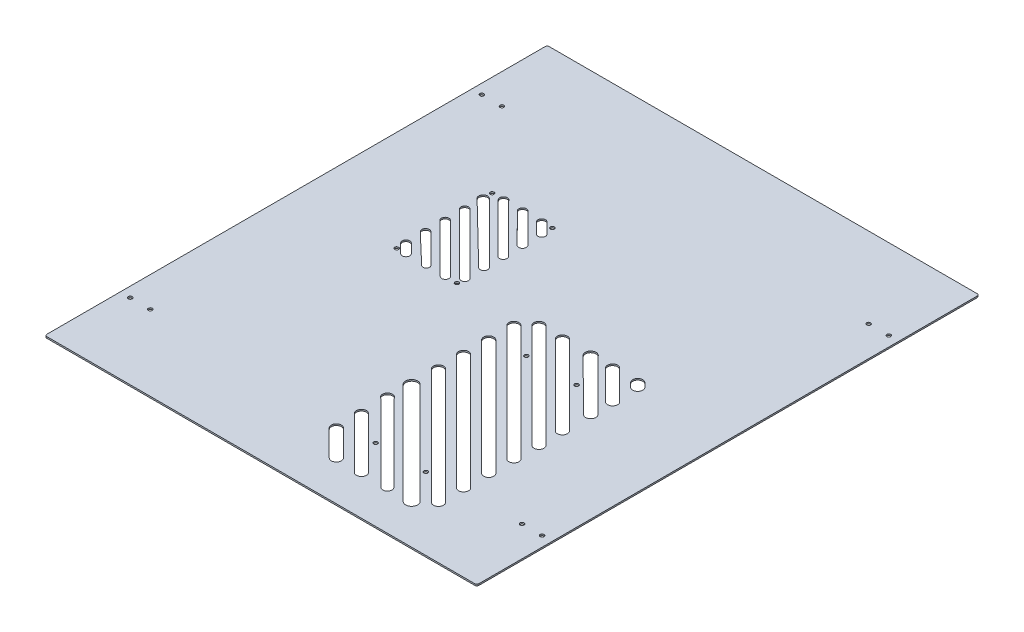
from build123d import *

# Parameters (mm, degrees)
SKETCH1_W           = 430
SKETCH1_H           = 500
BOSS_EXTRUDE1_DEPTH = 1.5
SKETCH12_R          = 1.95
CUT_EXTRUDE3_DEPTH  = 50.8
SKETCH6_R           = 1.95
CUT_EXTRUDE4_DEPTH  = 50.8
SKETCH7_R           = 1.95
CUT_EXTRUDE5_DEPTH  = 50.8
FILLET1_R           = 2
CUT_EXTRUDE6_DEPTH  = 10


with BuildPart() as part:
    # Sketch1 → Boss-Extrude1 (new body)
    with BuildSketch(Plane(origin=(0, 0, 0), x_dir=(1, 0, 0), z_dir=(0, 1, 0))):
        Rectangle(SKETCH1_W, SKETCH1_H)
    extrude(amount=BOSS_EXTRUDE1_DEPTH)

    # Sketch12 → Cut-Extrude3 (cut)
    with BuildSketch(Plane(origin=(0, 0, 0), x_dir=(-1, 0, 0), z_dir=(0, -1, 0))):
        with Locations((-185, -175)):
            Circle(SKETCH12_R)
        with Locations((-205, 170)):
            Circle(SKETCH12_R)
        with Locations((-205, -175)):
            Circle(SKETCH12_R)
        with Locations((-185, 170)):
            Circle(SKETCH12_R)
        with Locations((205, -175)):
            Circle(SKETCH12_R)
        with Locations((185, 175)):
            Circle(SKETCH12_R)
        with Locations((205, 175)):
            Circle(SKETCH12_R)
        with Locations((185, -175)):
            Circle(SKETCH12_R)
    extrude(amount=-CUT_EXTRUDE3_DEPTH, mode=Mode.SUBTRACT)

    # Sketch6 → Cut-Extrude4 (cut)
    with BuildSketch(Plane(origin=(0, 1.5, 0), x_dir=(1, 0, 0), z_dir=(0, 1, 0))):
        with Locations((92.292697989, -28)):
            Circle(SKETCH6_R)
        with Locations((42.292697989, -28)):
            Circle(SKETCH6_R)
        with Locations((92.292697989, -178)):
            Circle(SKETCH6_R)
        with Locations((42.292697989, -178)):
            Circle(SKETCH6_R)
    extrude(amount=-CUT_EXTRUDE4_DEPTH, mode=Mode.SUBTRACT)

    # Sketch7 → Cut-Extrude5 (cut)
    with BuildSketch(Plane(origin=(0, 1.5, 0), x_dir=(1, 0, 0), z_dir=(0, 1, 0))):
        with Locations((-114.979961576, 95.192396061)):
            Circle(SKETCH7_R)
        with Locations((-54.979961576, 95.192396061)):
            Circle(SKETCH7_R)
        with Locations((-54.979961576, 0.192396061)):
            Circle(SKETCH7_R)
        with Locations((-114.979961576, 0.192396061)):
            Circle(SKETCH7_R)
    extrude(amount=-CUT_EXTRUDE5_DEPTH, mode=Mode.SUBTRACT)

    # Fillet1
    fillet1_edges = [part.edges().sort_by_distance(p)[0] for p in [
        (215, 0.75, 250),
        (-215, 0.75, 250),
        (-215, 0.75, -250),
        (215, 0.75, -250),
    ]]
    fillet(fillet1_edges, radius=FILLET1_R)

    # Sketch13 → Cut-Extrude6 (cut)
    with BuildSketch(Plane.XZ):
        with BuildLine():
            ThreePointArc((128.328231895, 194.409545443), (128.328231895, 201.480613255), (121.257164083, 201.480613255))
            Line((121.257164083, 201.480613255), (6.257164083, 86.480613255))
            ThreePointArc((6.257164083, 86.480613255), (6.257164083, 79.409545443), (13.328231895, 79.409545443))
            Line((13.328231895, 79.409545443), (128.328231895, 194.409545443))
        make_face()
        with BuildLine():
            ThreePointArc((114.891555161, 206.259007204), (114.891555161, 214.740992796), (106.409569569, 214.740992796))
            Line((106.409569569, 214.740992796), (5.551705193, 113.883128419))
            ThreePointArc((5.551705193, 113.883128419), (5.551705193, 105.401142828), (14.033690785, 105.401142828))
            Line((14.033690785, 105.401142828), (114.891555161, 206.259007204))
        make_face()
        with BuildLine():
            ThreePointArc((128.328231895, 169.409545443), (128.328231895, 176.480613255), (121.257164083, 176.480613255))
            Line((121.257164083, 176.480613255), (6.257164083, 61.480613255))
            ThreePointArc((6.257164083, 61.480613255), (6.257164083, 54.409545443), (13.328231895, 54.409545443))
            Line((13.328231895, 54.409545443), (128.328231895, 169.409545443))
        make_face()
        with BuildLine():
            ThreePointArc((128.328231895, 144.409545443), (128.328231895, 151.480613255), (121.257164083, 151.480613255))
            Line((121.257164083, 151.480613255), (6.257164083, 36.480613255))
            ThreePointArc((6.257164083, 36.480613255), (6.257164083, 29.409545443), (13.328231895, 29.409545443))
            Line((13.328231895, 29.409545443), (128.328231895, 144.409545443))
        make_face()
        with BuildLine():
            ThreePointArc((7.050771569, 137.384062043), (5.156114678, 129.125444121), (13.4147326, 131.020101013))
            Line((13.4147326, 131.020101013), (89.712651072, 207.318019485))
            ThreePointArc((89.712651072, 207.318019485), (89.712651072, 213.681980515), (83.348690041, 213.681980515))
            Line((83.348690041, 213.681980515), (7.050771569, 137.384062043))
        make_face()
        with BuildLine():
            ThreePointArc((128.328231895, 119.409545443), (128.328231895, 126.480613255), (121.257164083, 126.480613255))
            Line((121.257164083, 126.480613255), (6.257164083, 11.480613255))
            ThreePointArc((6.257164083, 11.480613255), (6.257164083, 4.409545443), (13.328231895, 4.409545443))
            Line((13.328231895, 4.409545443), (128.328231895, 119.409545443))
        make_face()
        with BuildLine():
            ThreePointArc((129.178407924, 95.256425689), (129.178407924, 102.327493501), (122.107340112, 102.327493501))
            Line((122.107340112, 102.327493501), (18.815380517, -0.964466094))
            ThreePointArc((18.815380517, -0.964466094), (18.815380517, -8.035533906), (25.886448329, -8.035533906))
            Line((25.886448329, -8.035533906), (129.178407924, 95.256425689))
        make_face()
        with BuildLine():
            ThreePointArc((64.186096271, 206.964466094), (64.186096271, 214.035533906), (57.115028459, 214.035533906))
            Line((57.115028459, 214.035533906), (6.257164083, 163.17766953))
            ThreePointArc((6.257164083, 163.17766953), (6.257164083, 156.106601718), (13.328231895, 156.106601718))
            Line((13.328231895, 156.106601718), (64.186096271, 206.964466094))
        make_face()
        with BuildLine():
            ThreePointArc((128.328231895, 71.106601718), (128.328231895, 78.17766953), (121.257164083, 78.17766953))
            Line((121.257164083, 78.17766953), (42.115028459, -0.964466094))
            ThreePointArc((42.115028459, -0.964466094), (42.115028459, -8.035533906), (49.186096271, -8.035533906))
            Line((49.186096271, -8.035533906), (128.328231895, 71.106601718))
        make_face()
        with BuildLine():
            ThreePointArc((128.434071453, 42.778300689), (128.450410182, 50.077386347), (121.151324524, 50.093725076))
            Line((121.151324524, 50.093725076), (70.101549086, -0.728014801))
            ThreePointArc((70.101549086, -0.728014801), (70.211536159, -8.378376983), (77.854021235, -8.014288369))
            Line((77.854021235, -8.014288369), (80.943634504, -4.5))
            Line((80.943634504, -4.5), (128.434071453, 42.778300689))
        make_face()
        with BuildLine():
            ThreePointArc((39.186096271, 206.964466094), (39.186090231, 214.035539946), (32.11501638, 214.035521827))
            Line((32.11501638, 214.035521827), (28.579518712, 210.5))
            Line((28.579518712, 210.5), (6.257188241, 188.17766953))
            ThreePointArc((6.257188241, 188.17766953), (6.257176162, 181.106613797), (13.328231895, 181.106601718))
            Line((13.328231895, 181.106601718), (39.186096271, 206.964466094))
        make_face()
        with BuildLine():
            ThreePointArc((128.328231895, 21.106601718), (128.328231895, 28.17766953), (121.257164083, 28.17766953))
            Line((121.257164083, 28.17766953), (92.115028459, -0.964466094))
            ThreePointArc((92.115028459, -0.964466094), (92.115028459, -8.035533906), (99.186096271, -8.035533906))
            Line((99.186096271, -8.035533906), (128.328231895, 21.106601718))
        make_face()
        with BuildLine():
            ThreePointArc((128.328449123, -3.893615534), (128.328449135, 3.177669518), (121.257164083, 3.17766953))
            Line((121.257164083, 3.17766953), (117.115028459, -0.964466094))
            ThreePointArc((117.115028459, -0.964466094), (117.11493575, -8.035441194), (124.185910844, -8.035719323))
            Line((124.185910844, -8.035719323), (128.328449123, -3.893615534))
        make_face()
        with BuildLine():
            Line((-60.282225947, -95.192396061), (-54.979961576, -89.89013169))
            Line((-54.979961576, -89.89013169), (-52.328312545, -87.235758493))
            ThreePointArc((-52.328312545, -87.235758493), (-52.33035331, -81.93586188), (-57.630250273, -81.936542135))
            Line((-57.630250273, -81.936542135), (-68.235815502, -92.542107364))
            ThreePointArc((-68.235815502, -92.542107364), (-68.236495757, -97.842004327), (-62.936599144, -97.844045092))
            Line((-62.936599144, -97.844045092), (-60.282225947, -95.192396061))
        make_face()
        with BuildLine():
            Line((-79.432380406, -95.192396061), (-52.328311176, -68.084345475))
            ThreePointArc((-52.328311176, -68.084345475), (-52.332091228, -62.778048343), (-57.638379198, -62.788609103))
            Line((-57.638379198, -62.788609103), (-87.242774375, -92.549084557))
            ThreePointArc((-87.242774375, -92.549084557), (-87.193524879, -97.884311066), (-81.85941362, -97.764626075))
            Line((-81.85941362, -97.764626075), (-79.432380406, -95.192396061))
        make_face()
        with BuildLine():
            Line((-98.589718565, -95.192396061), (-54.979961576, -51.582639071))
            Line((-54.979961576, -51.582639071), (-52.328311176, -48.930599166))
            ThreePointArc((-52.328311176, -48.930599166), (-52.332818712, -43.623576712), (-57.639827781, -43.636319812))
            Line((-57.639827781, -43.636319812), (-106.244222321, -92.550540935))
            ThreePointArc((-106.244222321, -92.550540935), (-106.146641992, -97.928953998), (-100.773557317, -97.670477564))
            Line((-100.773557317, -97.670477564), (-98.589718565, -95.192396061))
        make_face()
        with BuildLine():
            Line((-111.925519092, -89.374450278), (-52.328311147, -29.777242332))
            ThreePointArc((-52.328311147, -29.777242332), (-52.310450744, -24.491922995), (-57.595528665, -24.438342602))
            Line((-57.595528665, -24.438342602), (-117.992839573, -83.224558883))
            ThreePointArc((-117.992839573, -83.224558883), (-118.054977502, -89.353737319), (-111.925519092, -89.374450278))
        make_face()
        with BuildLine():
            Line((-112.328311147, -70.623496023), (-52.374195212, -10.669380088))
            ThreePointArc((-52.374195212, -10.669380088), (-52.374195212, -5.457847361), (-57.58572794, -5.457847361))
            Line((-57.58572794, -5.457847361), (-114.979961576, -62.668544735))
            Line((-114.979961576, -62.668544735), (-117.631612006, -65.320195164))
            ThreePointArc((-117.631612006, -65.320195164), (-117.631612006, -70.623496023), (-112.328311147, -70.623496023))
        make_face()
        with BuildLine():
            Line((-112.328311147, -51.123496023), (-63.949411742, -2.744596618))
            ThreePointArc((-63.949411742, -2.744596618), (-63.936748679, 2.34707829), (-69.028297614, 2.385067165))
            Line((-69.028297614, 2.385067165), (-71.657559216, -0.192396061))
            Line((-71.657559216, -0.192396061), (-114.979961576, -43.514798421))
            Line((-114.979961576, -43.514798421), (-117.432443337, -45.634975273))
            ThreePointArc((-117.432443337, -45.634975273), (-117.726028226, -51.025591461), (-112.328311147, -51.123496023))
        make_face()
        with BuildLine():
            Line((-112.328311147, -31.623496023), (-83.202607923, -2.497792799))
            ThreePointArc((-83.202607923, -2.497792799), (-83.175365618, 2.085432584), (-87.75794332, 2.167155652))
            Line((-87.75794332, 2.167155652), (-117.567824527, -26.25790651))
            ThreePointArc((-117.567824527, -26.25790651), (-117.662945906, -31.591787403), (-112.328311147, -31.623496023))
        make_face()
        with BuildLine():
            Line((-112.328311147, -12.123496023), (-103.048861614, -2.84404649))
            ThreePointArc((-103.048861614, -2.84404649), (-103.048861614, 2.459254369), (-108.352162473, 2.459254369))
            Line((-108.352162473, 2.459254369), (-117.631612006, -6.820195164))
            ThreePointArc((-117.631612006, -6.820195164), (-117.631612006, -12.123496023), (-112.328311147, -12.123496023))
        make_face()
    extrude(amount=-CUT_EXTRUDE6_DEPTH, mode=Mode.SUBTRACT)


solid = part.part
